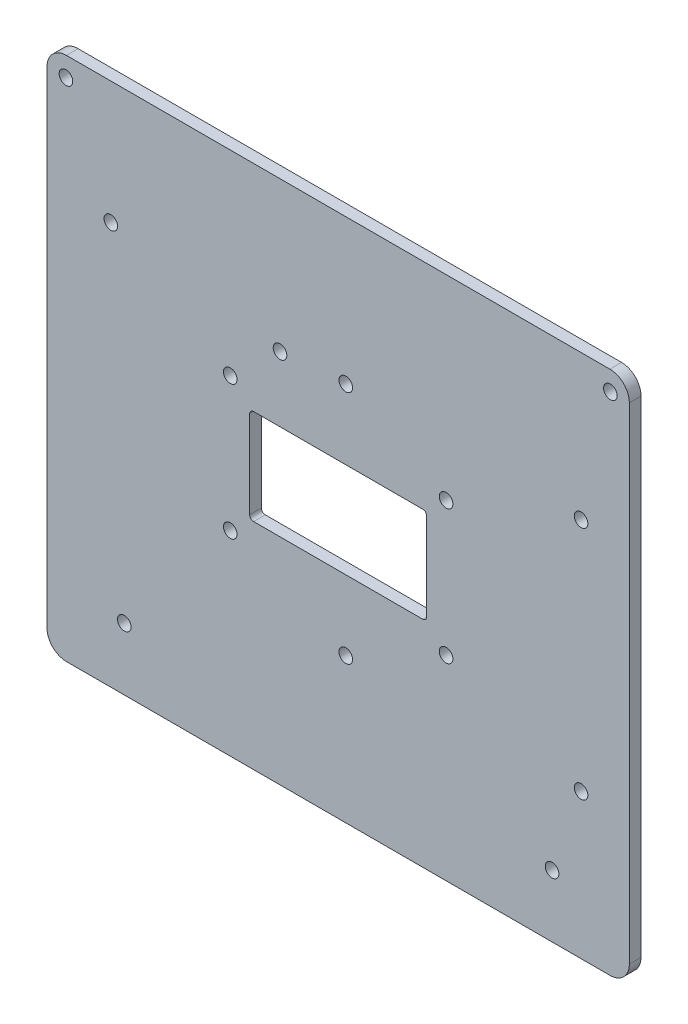
from build123d import *

# Parameters (mm, degrees)
ESQUISSE1_W        = 149.75
ESQUISSE1_H        = 135
ESQUISSE1_R        = 1.75
ESQUISSE1_W_2      = 45.5
ESQUISSE1_H_2      = 24.5
BOSS_EXTRU_1_DEPTH = 3
CONG_1_R           = 5
CONG_2_R           = 1


with BuildPart() as part:
    # Esquisse1 → Boss.-Extru.1 (new body)
    with BuildSketch(Plane.XY):
        Rectangle(ESQUISSE1_W, ESQUISSE1_H)
        with Locations((-70, 62.5)):
            Circle(ESQUISSE1_R, mode=Mode.SUBTRACT)
        with Locations((70, 62.5)):
            Circle(ESQUISSE1_R, mode=Mode.SUBTRACT)
        with Locations((55, -51.5)):
            Circle(ESQUISSE1_R, mode=Mode.SUBTRACT)
        with Locations((-55, -51.5)):
            Circle(ESQUISSE1_R, mode=Mode.SUBTRACT)
        with Locations((-58.458333333, 36)):
            Circle(ESQUISSE1_R, mode=Mode.SUBTRACT)
        with Locations((-14.958333333, 29)):
            Circle(ESQUISSE1_R, mode=Mode.SUBTRACT)
        with Locations((1.958333333, 30.25)):
            Circle(ESQUISSE1_R, mode=Mode.SUBTRACT)
        with Locations((62.458333333, 30.25)):
            Circle(ESQUISSE1_R, mode=Mode.SUBTRACT)
        with Locations((62.458333333, -30.25)):
            Circle(ESQUISSE1_R, mode=Mode.SUBTRACT)
        with Locations((1.958333333, -30.25)):
            Circle(ESQUISSE1_R, mode=Mode.SUBTRACT)
        with Locations((-27.75, 17.25)):
            Circle(ESQUISSE1_R, mode=Mode.SUBTRACT)
        with Locations((27.75, 17.25)):
            Circle(ESQUISSE1_R, mode=Mode.SUBTRACT)
        with Locations((27.75, -17.25)):
            Circle(ESQUISSE1_R, mode=Mode.SUBTRACT)
        with Locations((-27.75, -17.25)):
            Circle(ESQUISSE1_R, mode=Mode.SUBTRACT)
        Rectangle(ESQUISSE1_W_2, ESQUISSE1_H_2, mode=Mode.SUBTRACT)
    extrude(amount=BOSS_EXTRU_1_DEPTH)

    # Congé1
    cong_1_edges = [part.edges().sort_by_distance(p)[0] for p in [
        (-74.875, 67.5, 1.5),
        (74.875, 67.5, 1.5),
        (74.875, -67.5, 1.5),
        (-74.875, -67.5, 1.5),
    ]]
    fillet(cong_1_edges, radius=CONG_1_R)

    # Congé2
    cong_2_edges = [part.edges().sort_by_distance(p)[0] for p in [
        (-22.75, 12.25, 1.5),
        (-22.75, -12.25, 1.5),
        (22.75, -12.25, 1.5),
        (22.75, 12.25, 1.5),
    ]]
    fillet(cong_2_edges, radius=CONG_2_R)


solid = part.part
